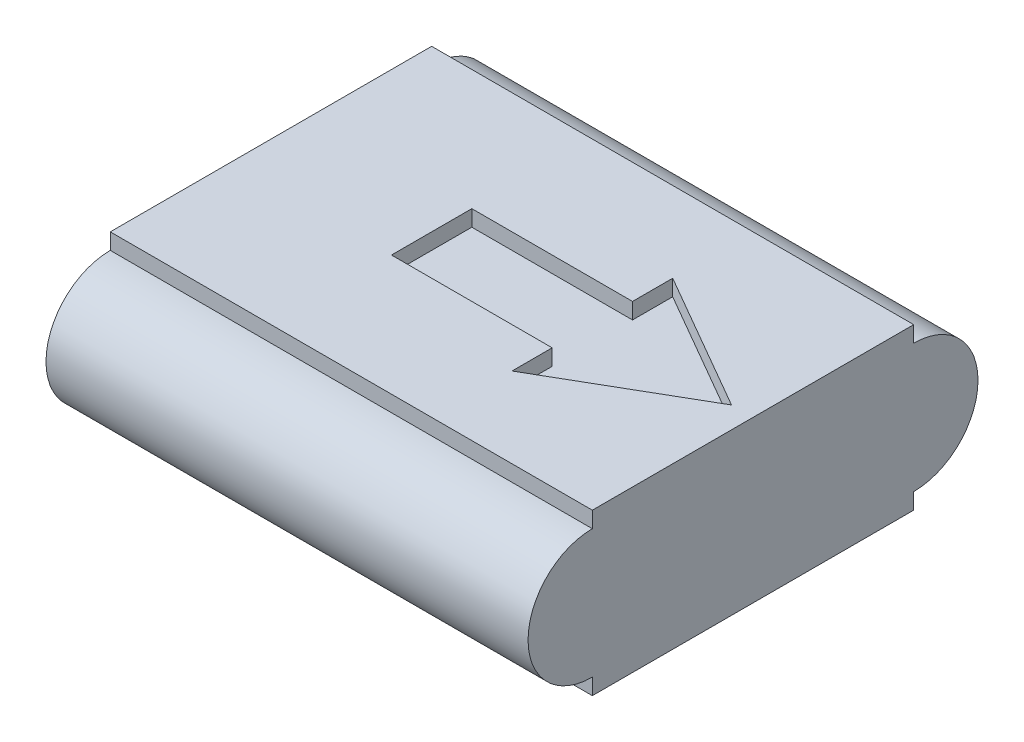
from build123d import *

# Parameters (mm, degrees)
SKETCH1_W           = 300
SKETCH1_H           = 200
BOSS_EXTRUDE2_DEPTH = 100
SKETCH2_R           = 40
BOSS_EXTRUDE3_DEPTH = 300
CUT_EXTRUDE1_DEPTH  = 10


with BuildPart() as part:
    # Sketch1 → Boss-Extrude2 (new body)
    with BuildSketch(Plane(origin=(0, 0, 0), x_dir=(1, 0, 0), z_dir=(0, 1, 0))):
        Rectangle(SKETCH1_W, SKETCH1_H)
    extrude(amount=BOSS_EXTRUDE2_DEPTH)

    # Sketch2 → Boss-Extrude3 (add)
    with BuildSketch(Plane.ZY.offset(150)):
        with Locations((100, 50)):
            Circle(SKETCH2_R)
        with Locations((-100, 50)):
            Circle(SKETCH2_R)
    extrude(amount=-BOSS_EXTRUDE3_DEPTH)

    # Sketch3 → Cut-Extrude1 (cut)
    with BuildSketch(Plane(origin=(0, 100, 0), x_dir=(1, 0, 0), z_dir=(0, 1, 0))):
        Polygon((50, 25), (50, 50), (136.602540378, 0), (50, -50), (50, -25), (-50, -25), (-50, 25), align=None)
    extrude(amount=-CUT_EXTRUDE1_DEPTH, mode=Mode.SUBTRACT)


solid = part.part
